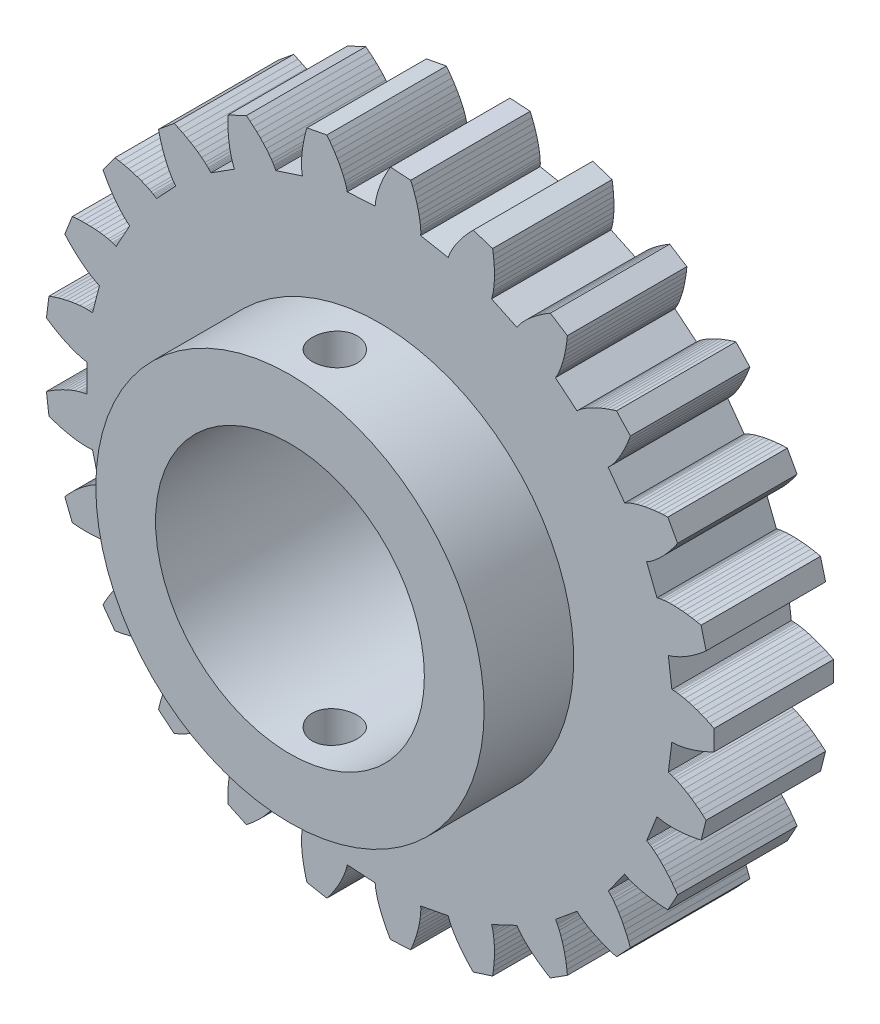
from build123d import *

# Parameters (mm, degrees)
MODEL_R             = 4.5
BOSS_EXTRUDE1_DEPTH = 4
SKETCH2_R           = 6.5
SKETCH2_R_2         = 4.5
BOSS_EXTRUDE2_DEPTH = 3
SKETCH3_R           = 0.75
CUT_EXTRUDE2_DEPTH  = 24.9295596


with BuildPart() as part:
    # Model → Boss-Extrude1 (new body)
    with BuildSketch(Plane.XY):
        Polygon((22.5153116, 13.49371), (22.5501244, 13.4944492), (22.5850516, 13.4935692), (22.6200756, 13.4916244), (22.6551524, 13.4887996), (22.7254732, 13.4809588), (22.7959612, 13.4705748), (22.9373156, 13.4433212), (23.0790396, 13.4084996), (23.2209836, 13.3669196), (23.3630332, 13.319118), (23.5050916, 13.2654556), (23.6470444, 13.2062052), (23.7888124, 13.1415956), (23.93029, 13.071794), (23.93029, 12.391466), (23.7888124, 12.3216644), (23.6470444, 12.257046), (23.5050916, 12.1978044), (23.3630332, 12.144142), (23.2209836, 12.0963316), (23.0790396, 12.0547516), (22.9373156, 12.01993), (22.7959612, 11.9926764), (22.7254732, 11.9822924), (22.6551524, 11.9744516), (22.6200756, 11.9716356), (22.5850516, 11.969682), (22.5501244, 11.9688108), (22.5153116, 11.96955), (22.397462, 11.036662), (22.4313596, 11.0287244), (22.4649756, 11.0191852), (22.4984068, 11.00859), (22.5316884, 10.9971324), (22.5978468, 10.9720524), (22.6635388, 10.9444644), (22.7936732, 10.8829084), (22.9222852, 10.8139428), (23.0494276, 10.7383684), (23.1751356, 10.6567396), (23.299374, 10.569426), (23.4221428, 10.4767444), (23.5433804, 10.378906), (23.6630604, 10.2761132), (23.4938716, 9.6171516), (23.3394756, 9.5847324), (23.1860916, 9.5574084), (23.0338604, 9.5353204), (22.8829228, 9.5186708), (22.733446, 9.5076972), (22.5856236, 9.5027252), (22.4396932, 9.5042388), (22.295998, 9.5129948), (22.2251404, 9.5204748), (22.1550836, 9.5303572), (22.1204028, 9.53635), (22.0860036, 9.5431788), (22.0519476, 9.5510108), (22.0184196, 9.5603828), (21.6722716, 8.6861204), (21.7031332, 8.6699988), (21.7333172, 8.6523988), (21.76307, 8.633822), (21.7924532, 8.6144532), (21.8502868, 8.5737004), (21.9070556, 8.530642), (22.0178036, 8.4386644), (22.1252164, 8.3398756), (22.2295756, 8.2350588), (22.331022, 8.1247332), (22.4296524, 8.0092684), (22.5255108, 7.8889636), (22.6186148, 7.7640476), (22.7089732, 7.634714), (22.3812172, 7.0385404), (22.2236092, 7.0455364), (22.068254, 7.0572052), (21.91531, 7.0736788), (21.7649708, 7.0950892), (21.6174652, 7.12163), (21.4730484, 7.153574), (21.3320812, 7.1913348), (21.195074, 7.2355548), (21.1283084, 7.2604148), (21.0629068, 7.2874132), (21.0308044, 7.3018452), (20.999186, 7.3170076), (20.9681484, 7.3330676), (20.9379996, 7.3504828), (20.3853068, 6.5897668), (20.4111876, 6.566482), (20.4360564, 6.5419212), (20.4602476, 6.5165332), (20.4838844, 6.4904676), (20.5297764, 6.4366116), (20.5740492, 6.3807932), (20.6584412, 6.264158), (20.737914, 6.1417588), (20.8129252, 6.014282), (20.8837564, 5.882194), (20.950566, 5.7458292), (21.0134948, 5.6054604), (21.0726132, 5.4613164), (21.1279652, 5.313582), (20.6622428, 4.8176404), (20.5113228, 4.8636116), (20.3637556, 4.9135604), (20.2197172, 4.9675484), (20.0794276, 5.0256724), (19.9431508, 5.0880556), (19.8112124, 5.154918), (19.6840612, 5.22655), (19.562366, 5.3034532), (19.5038724, 5.3441356), (19.4472444, 5.3865516), (19.4197444, 5.4085076), (19.392878, 5.431062), (19.3668124, 5.454338), (19.3419436, 5.4787052), (18.6174308, 4.8793372), (18.6367116, 4.8503412), (18.65469, 4.8203684), (18.671806, 4.789762), (18.6882268, 4.7586364), (18.7192732, 4.6950564), (18.748278, 4.6299804), (18.8010076, 4.4960268), (18.8475508, 4.3577084), (18.888506, 4.2155796), (18.9242516, 4.0700276), (18.9550604, 3.921334), (18.9810996, 3.7697276), (19.00251, 3.6154108), (19.0193796, 3.4585508), (18.4449596, 3.0940108), (18.310214, 3.1760708), (18.1797012, 3.2611404), (18.0536148, 3.3492548), (17.9321836, 3.4404404), (17.8157068, 3.5347676), (17.7045452, 3.6323332), (17.5992092, 3.7333396), (17.5004468, 3.838086), (17.4539124, 3.8920388), (17.4096132, 3.947206), (17.3884316, 3.9753132), (17.3680332, 4.003834), (17.3485676, 4.0328564), (17.3305364, 4.0626444), (16.4797348, 3.6622884), (16.4911924, 3.6294116), (16.501154, 3.59591), (16.5101212, 3.5620124), (16.5182788, 3.5277716), (16.5325524, 3.4584716), (16.5444588, 3.38823), (16.5622172, 3.2453708), (16.5729004, 3.0998188), (16.5772212, 2.9519788), (16.575646, 2.802106), (16.5685092, 2.6504204), (16.5560308, 2.497098), (16.5383868, 2.342306), (16.515718, 2.1861764), (15.8686892, 1.9759444), (15.7585836, 2.0889364), (15.6533268, 2.203794), (15.5531124, 2.3204996), (15.458178, 2.439018), (15.368814, 2.5593404), (15.2854076, 2.6814932), (15.2084956, 2.8055204), (15.1388964, 2.9315364), (15.107234, 2.9953628), (15.0780444, 3.059814), (15.0645276, 3.0923036), (15.0518556, 3.1250044), (15.040222, 3.1579604), (15.0301724, 3.1912948), (14.1065244, 3.0151012), (14.1094548, 2.9804116), (14.110766, 2.9454844), (14.1110212, 2.9104164), (14.110414, 2.8752252), (14.1069996, 2.8045612), (14.1010596, 2.733554), (14.082738, 2.5907652), (14.0568836, 2.4471404), (14.024306, 2.3028644), (13.9855068, 2.1580868), (13.9408732, 2.0129484), (13.8906516, 1.867546), (13.8350708, 1.7220028), (13.7742892, 1.5764156), (13.0953076, 1.5337004), (13.0167588, 1.6705228), (12.9433668, 1.8079524), (12.8753252, 1.94591), (12.8128452, 2.0843076), (12.7562172, 2.2230836), (12.7058108, 2.3621324), (12.662154, 2.5013924), (12.6260828, 2.640758), (12.61129, 2.710454), (12.5990492, 2.7801412), (12.5940332, 2.8149716), (12.5898884, 2.849802), (12.5868172, 2.8846148), (12.585374, 2.9194012), (11.6469332, 2.9784404), (11.641134, 2.9441116), (11.6337244, 2.9099588), (11.62525, 2.8759292), (11.6159044, 2.8419964), (11.5950308, 2.7743948), (11.5716228, 2.7071012), (11.5183564, 2.57335), (11.4576012, 2.4406636), (11.390158, 2.3090244), (11.3165812, 2.17845), (11.2372492, 2.0489668), (11.1524524, 1.9206276), (11.0624196, 1.7934764), (10.9673444, 1.6675836), (10.2990636, 1.7950604), (10.2570084, 1.9471156), (10.22011, 2.0984756), (10.188518, 2.249026), (10.1624172, 2.3986172), (10.1420716, 2.5471084), (10.1278332, 2.6943324), (10.120186, 2.8400692), (10.1199044, 2.9840284), (10.122914, 3.0552116), (10.1283788, 3.1257524), (10.1321804, 3.1607412), (10.1368356, 3.1955012), (10.1425204, 3.2299884), (10.1497628, 3.2640444), (9.2554892, 3.5546116), (9.2413388, 3.5227996), (9.225666, 3.4915596), (9.2089988, 3.4607068), (9.1915132, 3.430162), (9.154474, 3.369882), (9.1150676, 3.3105172), (9.030218, 3.1942252), (8.9383724, 3.0808108), (8.840314, 2.9700804), (8.7365708, 2.861902), (8.62753, 2.756214), (8.513482, 2.6529988), (8.3946556, 2.55223), (8.2712532, 2.453934), (7.6556756, 2.7436036), (7.6527628, 2.9013436), (7.6546548, 3.05713), (7.6614924, 3.2108044), (7.6734164, 3.362182), (7.6906468, 3.5110692), (7.7134652, 3.6572108), (7.742294, 3.8002724), (7.7778196, 3.9397788), (7.798438, 4.0079788), (7.8212828, 4.0749468), (7.8336732, 4.1078852), (7.8468204, 4.1404012), (7.8608916, 4.1723804), (7.8763884, 4.2035676), (7.08247, 4.7074028), (7.0608484, 4.6801052), (7.0379068, 4.6537492), (7.0140852, 4.6280092), (6.9895508, 4.6027796), (6.938678, 4.5535964), (6.8857548, 4.5059004), (6.774646, 4.4143628), (6.6574828, 4.3273572), (6.5349692, 4.2444876), (6.4075804, 4.1655076), (6.275686, 4.0902588), (6.13955, 4.0186444), (5.9994012, 3.9506028), (5.8554332, 3.8860812), (5.331226, 4.3197364), (5.3676316, 4.4732436), (5.4082084, 4.623662), (5.4530444, 4.7708068), (5.5022452, 4.9144668), (5.5559604, 5.0543956), (5.6144012, 5.1902676), (5.6779108, 5.3216604), (5.7470084, 5.4479492), (5.783942, 5.5088804), (5.8227236, 5.5680604), (5.8429108, 5.5968892), (5.8637316, 5.6251108), (5.885318, 5.6525932), (5.9080836, 5.6789404), (5.2643988, 6.36439), (5.2366788, 6.3433316), (5.207894, 6.3235052), (5.1784228, 6.3044972), (5.1483884, 6.286158), (5.0868852, 6.2511692), (5.023754, 6.2181428), (4.8933732, 6.157106), (4.758258, 6.101974), (4.6189804, 6.0521748), (4.475954, 6.0073564), (4.3294868, 5.9672724), (4.1798164, 5.9317644), (4.027154, 5.9007092), (3.871658, 5.8740188), (3.4717684, 6.4244148), (3.5452044, 6.5640532), (3.6219228, 6.6996436), (3.7019412, 6.8310188), (3.7853212, 6.9579324), (3.872142, 7.0801028), (3.9625444, 7.197178), (4.0567308, 7.3086476), (4.1550708, 7.4137812), (4.2059964, 7.4636156), (4.2582684, 7.511294), (4.284994, 7.5341916), (4.3121772, 7.55635), (4.3399236, 7.577602), (4.3685236, 7.5974636), (3.9155348, 8.4214516), (3.8834412, 8.4079436), (3.8506348, 8.3959052), (3.817362, 8.384826), (3.783702, 8.37453), (3.7154316, 8.3559356), (3.6460788, 8.3396468), (3.50461, 8.3129476), (3.360026, 8.2931564), (3.2127404, 8.2795516), (3.0630612, 8.2717108), (2.9112348, 8.2693172), (2.7574372, 8.272142), (2.6018356, 8.2800268), (2.4445972, 8.2928484), (2.1941492, 8.9254012), (2.2999956, 9.0423884), (2.4080244, 9.15465), (2.5182004, 9.2619924), (2.6305236, 9.364178), (2.7450028, 9.4609252), (2.8616732, 9.5518292), (2.9806316, 9.6363796), (3.1020276, 9.713758), (3.163742, 9.7493628), (3.2262308, 9.7825388), (3.257814, 9.7980708), (3.2896524, 9.8127756), (3.3218076, 9.8264508), (3.3544468, 9.8385772), (3.1206044, 10.7493332), (3.0861612, 10.744238), (3.0513924, 10.7407356), (3.0164124, 10.7382716), (2.9812564, 10.7366788), (2.9105044, 10.7356404), (2.8392772, 10.73711), (2.6956172, 10.7464292), (2.550646, 10.7632196), (2.40461, 10.7866804), (2.2576852, 10.8163012), (2.1100212, 10.8517388), (1.9617588, 10.8927292), (1.8130124, 10.9390612), (1.6638964, 10.9905764), (1.5786332, 11.6655452), (1.7102548, 11.7525332), (1.8428004, 11.8343996), (1.9762172, 11.9109684), (2.1104172, 11.9820196), (2.2453652, 12.0472452), (2.3809732, 12.1062932), (2.5172148, 12.1586004), (2.654046, 12.2033572), (2.7226772, 12.2224884), (2.791458, 12.2390852), (2.8259012, 12.2462748), (2.8603972, 12.252602), (2.894946, 12.2578468), (2.9295828, 12.2614812), (2.9295828, 13.2017788), (2.894946, 13.2054044), (2.8603972, 13.210658), (2.8259012, 13.2169764), (2.791458, 13.224166), (2.7226772, 13.2407628), (2.654046, 13.2599028), (2.5172148, 13.3046596), (2.3809732, 13.3569668), (2.2453652, 13.416006), (2.1104172, 13.4812404), (1.9762172, 13.5522828), (1.8428004, 13.6288604), (1.7102548, 13.7107268), (1.5786332, 13.797706), (1.6638964, 14.4726748), (1.8130124, 14.5241988), (1.9617588, 14.5705308), (2.1100212, 14.6115124), (2.2576852, 14.64695), (2.40461, 14.6765796), (2.550646, 14.7000404), (2.6956172, 14.716822), (2.8392772, 14.7261412), (2.9105044, 14.7276108), (2.9812564, 14.7265812), (3.0164124, 14.7249796), (3.0513924, 14.7225244), (3.0861612, 14.7190132), (3.1206044, 14.713918), (3.3544468, 15.624674), (3.3218076, 15.6368004), (3.2896524, 15.6504844), (3.257814, 15.6651804), (3.2262308, 15.6807124), (3.163742, 15.7138972), (3.1020276, 15.7494932), (2.9806316, 15.8268716), (2.8616732, 15.911422), (2.7450028, 16.0023348), (2.6305236, 16.0990732), (2.5182004, 16.2012676), (2.4080244, 16.30861), (2.2999956, 16.4208716), (2.1941492, 16.5378588), (2.4445972, 17.1704116), (2.6018356, 17.1832244), (2.7574372, 17.1911092), (2.9112348, 17.1939428), (3.0630612, 17.1915404), (3.2127404, 17.1836996), (3.360026, 17.1701036), (3.50461, 17.1503124), (3.6460788, 17.1236132), (3.7154316, 17.1073156), (3.783702, 17.0887212), (3.817362, 17.078434), (3.8506348, 17.0673548), (3.8834412, 17.0553076), (3.9155348, 17.0418084), (4.3685236, 17.8657964), (4.3399236, 17.885658), (4.3121772, 17.9069012), (4.284994, 17.9290596), (4.2582684, 17.9519572), (4.2059964, 17.9996356), (4.1550708, 18.04947), (4.0567308, 18.1546036), (3.9625444, 18.266082), (3.872142, 18.3831484), (3.7853212, 18.5053188), (3.7019412, 18.6322324), (3.6219228, 18.7636076), (3.5452044, 18.8992068), (3.4717684, 19.0388364), (3.871658, 19.5892412), (4.027154, 19.5625508), (4.1798164, 19.5314868), (4.3294868, 19.4959788), (4.475954, 19.4559036), (4.6189804, 19.4110764), (4.758258, 19.361286), (4.8933732, 19.306154), (5.023754, 19.2451172), (5.0868852, 19.212082), (5.1483884, 19.1770932), (5.1784228, 19.158754), (5.207894, 19.1397548), (5.2366788, 19.1199284), (5.2643988, 19.09887), (5.9080836, 19.7843108), (5.885318, 19.8106668), (5.8637316, 19.8381404), (5.8429108, 19.866362), (5.8227236, 19.8951908), (5.783942, 19.9543708), (5.7470084, 20.015302), (5.6779108, 20.1415908), (5.6144012, 20.2729836), (5.5559604, 20.4088644), (5.5022452, 20.5487844), (5.4530444, 20.6924532), (5.4082084, 20.839598), (5.3676316, 20.9900076), (5.331226, 21.1435236), (5.8554332, 21.5771788), (5.9994012, 21.5126572), (6.13955, 21.4446068), (6.275686, 21.3729924), (6.4075804, 21.2977436), (6.5349692, 21.2187636), (6.6574828, 21.135894), (6.774646, 21.0488972), (6.8857548, 20.9573508), (6.938678, 20.9096548), (6.9895508, 20.8604804), (7.0140852, 20.835242), (7.0379068, 20.809502), (7.0608484, 20.783146), (7.08247, 20.7558572), (7.8763884, 21.2596924), (7.8608916, 21.2908708), (7.8468204, 21.3228588), (7.8336732, 21.355366), (7.8212828, 21.3883132), (7.798438, 21.4552724), (7.7778196, 21.5234724), (7.742294, 21.6629876), (7.7134652, 21.8060404), (7.6906468, 21.952182), (7.6734164, 22.1010692), (7.6614924, 22.2524556), (7.6546548, 22.40613), (7.6527628, 22.5619076), (7.6556756, 22.7196476), (8.2712532, 23.0093172), (8.3946556, 22.9110212), (8.513482, 22.8102612), (8.62753, 22.7070372), (8.7365708, 22.6013492), (8.840314, 22.4931708), (8.9383724, 22.3824404), (9.030218, 22.2690348), (9.1150676, 22.152734), (9.154474, 22.093378), (9.1915132, 22.0330892), (9.2089988, 22.0025532), (9.225666, 21.9716916), (9.2413388, 21.9404604), (9.2554892, 21.9086484), (10.1497628, 22.1992156), (10.1425204, 22.2332716), (10.1368356, 22.26775), (10.1321804, 22.30251), (10.1283788, 22.3374988), (10.122914, 22.4080396), (10.1199044, 22.4792228), (10.120186, 22.623182), (10.1278332, 22.7689188), (10.1420716, 22.9161428), (10.1624172, 23.064634), (10.188518, 23.214234), (10.22011, 23.3647756), (10.2570084, 23.5161356), (10.2990636, 23.6681908), (10.9673444, 23.7956764), (11.0624196, 23.6697748), (11.1524524, 23.5426324), (11.2372492, 23.4142932), (11.3165812, 23.28481), (11.390158, 23.1542268), (11.4576012, 23.0225876), (11.5183564, 22.8899012), (11.5716228, 22.7561588), (11.5950308, 22.6888652), (11.6159044, 22.6212636), (11.62525, 22.5873308), (11.6337244, 22.5533012), (11.641134, 22.5191484), (11.6469332, 22.4848108), (12.585374, 22.5438588), (12.5868172, 22.5786452), (12.5898884, 22.613458), (12.5940332, 22.6482796), (12.5990492, 22.68311), (12.61129, 22.7527972), (12.6260828, 22.8224932), (12.662154, 22.9618676), (12.7058108, 23.1011188), (12.7562172, 23.2401764), (12.8128452, 23.3789436), (12.8753252, 23.51735), (12.9433668, 23.6553076), (13.0167588, 23.7927372), (13.0953076, 23.9295596), (13.7742892, 23.8868356), (13.8350708, 23.7412484), (13.8906516, 23.5957052), (13.9408732, 23.4503116), (13.9855068, 23.3051644), (14.024306, 23.1603956), (14.0568836, 23.0161196), (14.082738, 22.872486), (14.1010596, 22.7296972), (14.1069996, 22.6586988), (14.110414, 22.588026), (14.1110212, 22.5528348), (14.110766, 22.5177668), (14.1094548, 22.4828484), (14.1065244, 22.44815), (15.0301724, 22.2719564), (15.040222, 22.3052908), (15.0518556, 22.3382468), (15.0645276, 22.3709476), (15.0780444, 22.4034372), (15.107234, 22.4678884), (15.1388964, 22.5317236), (15.2084956, 22.6577396), (15.2854076, 22.7817668), (15.368814, 22.9039108), (15.458178, 23.024242), (15.5531124, 23.1427604), (15.6533268, 23.2594572), (15.7585836, 23.3743236), (15.8686892, 23.4873068), (16.515718, 23.2770748), (16.5383868, 23.1209452), (16.5560308, 22.9661532), (16.5685092, 22.8128396), (16.575646, 22.661154), (16.5772212, 22.5112812), (16.5729004, 22.3634324), (16.5622172, 22.2178892), (16.5444588, 22.07503), (16.5325524, 22.0047796), (16.5182788, 21.9354796), (16.5101212, 21.9012476), (16.501154, 21.8673412), (16.4911924, 21.8338484), (16.4797348, 21.8009628), (17.3305364, 21.4006068), (17.3485676, 21.4303948), (17.3680332, 21.4594172), (17.3884316, 21.4879468), (17.4096132, 21.516054), (17.4539124, 21.5712212), (17.5004468, 21.625174), (17.5992092, 21.7299204), (17.7045452, 21.830918), (17.8157068, 21.9284924), (17.9321836, 22.0228108), (18.0536148, 22.1139964), (18.1797012, 22.2021108), (18.310214, 22.2871892), (18.4449596, 22.3692404), (19.0193796, 22.0047092), (19.00251, 21.8478404), (18.9810996, 21.6935236), (18.9550604, 21.541926), (18.9242516, 21.3932324), (18.888506, 21.2476716), (18.8475508, 21.1055428), (18.8010076, 20.9672332), (18.748278, 20.8332708), (18.7192732, 20.7681948), (18.6882268, 20.7046236), (18.671806, 20.6734892), (18.65469, 20.6428828), (18.6367116, 20.6129188), (18.6174308, 20.5839228), (19.3419436, 19.9845548), (19.3668124, 20.008922), (19.392878, 20.032198), (19.4197444, 20.0547436), (19.4472444, 20.0767084), (19.5038724, 20.1191244), (19.562366, 20.1598068), (19.6840612, 20.2367012), (19.8112124, 20.3083332), (19.9431508, 20.3751956), (20.0794276, 20.4375876), (20.2197172, 20.4957116), (20.3637556, 20.5496996), (20.5113228, 20.5996396), (20.6622428, 20.6456108), (21.1279652, 20.1496692), (21.0726132, 20.0019348), (21.0134948, 19.8577908), (20.950566, 19.7174308), (20.8837564, 19.581066), (20.8129252, 19.448978), (20.737914, 19.3215012), (20.6584412, 19.199102), (20.5740492, 19.0824668), (20.5297764, 19.0266484), (20.4838844, 18.9727924), (20.4602476, 18.946718), (20.4360564, 18.92133), (20.4111876, 18.896778), (20.3853068, 18.8734844), (20.9379996, 18.1127684), (20.9681484, 18.1301836), (20.999186, 18.1462436), (21.0308044, 18.161406), (21.0629068, 18.175838), (21.1283084, 18.2028452), (21.195074, 18.2277052), (21.3320812, 18.2719164), (21.4730484, 18.3096772), (21.6174652, 18.34163), (21.7649708, 18.3681708), (21.91531, 18.3895724), (22.068254, 18.406046), (22.2236092, 18.4177236), (22.3812172, 18.4247108), (22.7089732, 17.8285372), (22.6186148, 17.6992124), (22.5255108, 17.5742964), (22.4296524, 17.4539916), (22.331022, 17.3385268), (22.2295756, 17.2282012), (22.1252164, 17.1233844), (22.0178036, 17.0245956), (21.9070556, 16.9326092), (21.8502868, 16.8895508), (21.7924532, 16.8488068), (21.76307, 16.8294292), (21.7333172, 16.8108612), (21.7031332, 16.7932612), (21.6722716, 16.7771308), (22.0184196, 15.9028684), (22.0519476, 15.9122404), (22.0860036, 15.9200812), (22.1204028, 15.9269012), (22.1550836, 15.932894), (22.2251404, 15.9427852), (22.295998, 15.9502564), (22.4396932, 15.9590124), (22.5856236, 15.9605348), (22.733446, 15.9555628), (22.8829228, 15.9445804), (23.0338604, 15.9279308), (23.1860916, 15.9058516), (23.3394756, 15.8785276), (23.4938716, 15.8460996), (23.6630604, 15.1871468), (23.5433804, 15.084354), (23.4221428, 14.9865156), (23.299374, 14.8938252), (23.1751356, 14.8065204), (23.0494276, 14.7248828), (22.9222852, 14.6493172), (22.7936732, 14.5803428), (22.6635388, 14.5187868), (22.5978468, 14.4912076), (22.5316884, 14.4661188), (22.4984068, 14.4546612), (22.4649756, 14.4440748), (22.4313596, 14.4345356), (22.397462, 14.4265892), align=None)
        with Locations((12.73163, 12.73163)):
            Circle(MODEL_R, mode=Mode.SUBTRACT)
    extrude(amount=BOSS_EXTRUDE1_DEPTH)

    # Sketch2 → Boss-Extrude2 (add)
    with BuildSketch(Plane.XY.offset(4)):
        with Locations((12.73163, 12.73163)):
            Circle(SKETCH2_R)
        with Locations((12.73163, 12.73163)):
            Circle(SKETCH2_R_2, mode=Mode.SUBTRACT)
    extrude(amount=BOSS_EXTRUDE2_DEPTH)

    # Sketch3 → Cut-Extrude2 (cut, through all)
    with BuildSketch(Plane.XZ):
        with Locations((12.73163, 5.5)):
            Circle(SKETCH3_R)
    extrude(amount=-CUT_EXTRUDE2_DEPTH, mode=Mode.SUBTRACT)


solid = part.part
